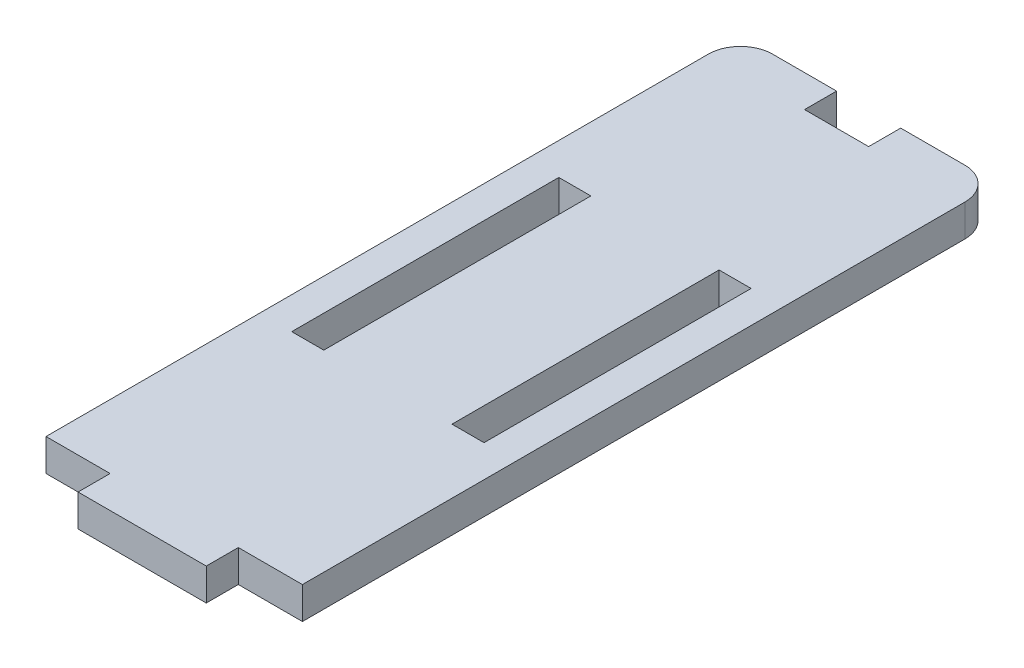
from build123d import *

# Parameters (mm, degrees)
SKETCH1_W               = 24
SKETCH1_H               = 65
BOSS_EXTRUDE1_DEPTH     = 1.5
SKETCH2_W               = 12
SKETCH2_H               = 3
BOSS_EXTRUDE2_DEPTH     = 1.5
SKETCH4_W               = 3
SKETCH4_H               = 25
CUT_EXTRUDE1_DEPTH      = 2.5
CUT_EXTRUDE1_DEPTH_BACK = 2.5
FILLET1_R               = 3
SKETCH5_W               = 6
SKETCH5_H               = 3
CUT_EXTRUDE2_DEPTH      = 2.5
CUT_EXTRUDE2_DEPTH_BACK = 2.5


with BuildPart() as part:
    # Sketch1 → Boss-Extrude1 (new body, symmetric)
    with BuildSketch(Plane(origin=(0, 0, 0), x_dir=(1, 0, 0), z_dir=(0, 1, 0))):
        Rectangle(SKETCH1_W, SKETCH1_H)
    extrude(amount=BOSS_EXTRUDE1_DEPTH, both=True)

    # Sketch2 → Boss-Extrude2 (add, symmetric)
    with BuildSketch(Plane(origin=(0, 0, 0), x_dir=(1, 0, 0), z_dir=(0, 1, 0))):
        with Locations((0, -34)):
            Rectangle(SKETCH2_W, SKETCH2_H)
    extrude(amount=BOSS_EXTRUDE2_DEPTH, both=True)

    # Sketch4 → Cut-Extrude1 (cut, two sides)
    with BuildSketch(Plane(origin=(0, 0, 0), x_dir=(1, 0, 0), z_dir=(0, 1, 0))) as cut_extrude1_sk:
        with Locations((-7.5, 0)):
            Rectangle(SKETCH4_W, SKETCH4_H)
        with Locations((7.5, 0)):
            Rectangle(SKETCH4_W, SKETCH4_H)
    extrude(amount=CUT_EXTRUDE1_DEPTH, mode=Mode.SUBTRACT)
    extrude(cut_extrude1_sk.sketch, amount=-CUT_EXTRUDE1_DEPTH_BACK, mode=Mode.SUBTRACT)

    # Fillet1
    fillet1_edges = [part.edges().sort_by_distance(p)[0] for p in [
        (-12, 0, -32.5),
        (12, 0, -32.5),
    ]]
    fillet(fillet1_edges, radius=FILLET1_R)

    # Sketch5 → Cut-Extrude2 (cut, two sides)
    with BuildSketch(Plane(origin=(0, 0, 0), x_dir=(1, 0, 0), z_dir=(0, 1, 0))) as cut_extrude2_sk:
        with Locations((0, 31)):
            Rectangle(SKETCH5_W, SKETCH5_H)
    extrude(amount=CUT_EXTRUDE2_DEPTH, mode=Mode.SUBTRACT)
    extrude(cut_extrude2_sk.sketch, amount=-CUT_EXTRUDE2_DEPTH_BACK, mode=Mode.SUBTRACT)


solid = part.part
